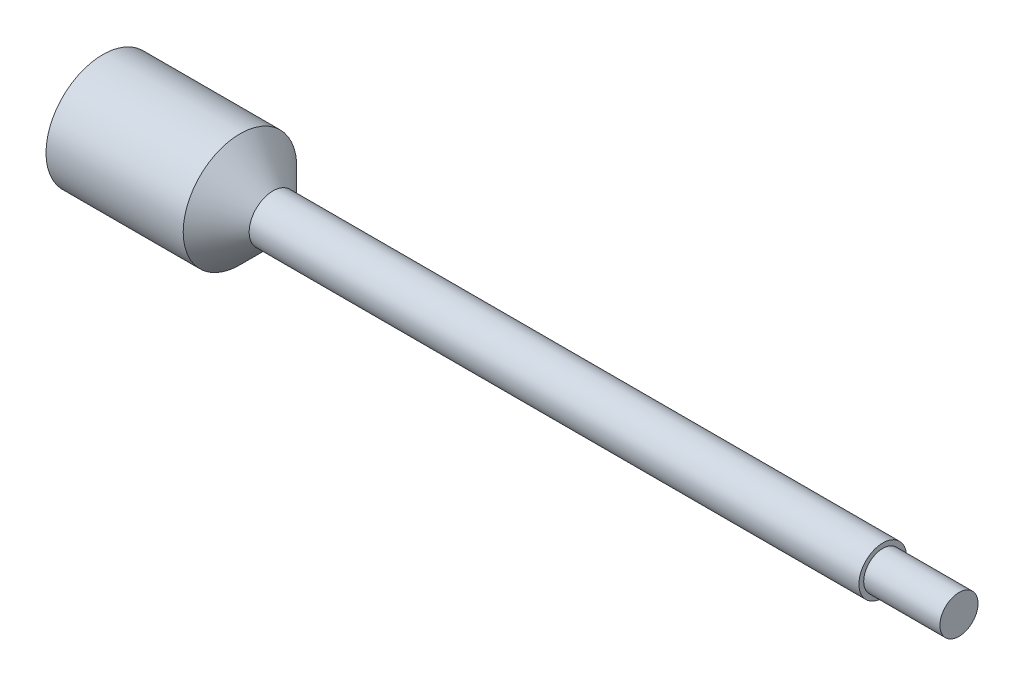
from build123d import *


with BuildPart() as part:
    # Sketch1 one side → Revolve1 (revolve)
    with BuildSketch(Plane.XY):
        Polygon((-55.841161068, 9.4615), (-55.841161068, 0), (86.811588932, 0), (86.811588932, 3.175), (74.111588932, 3.175), (74.111588932, 3.96875), (-27.488411068, 3.96875), (-32.981161068, 9.4615), align=None)
    revolve(axis=Axis((-55.841161068, 0, 0), (1, 0, 0)))


solid = part.part
